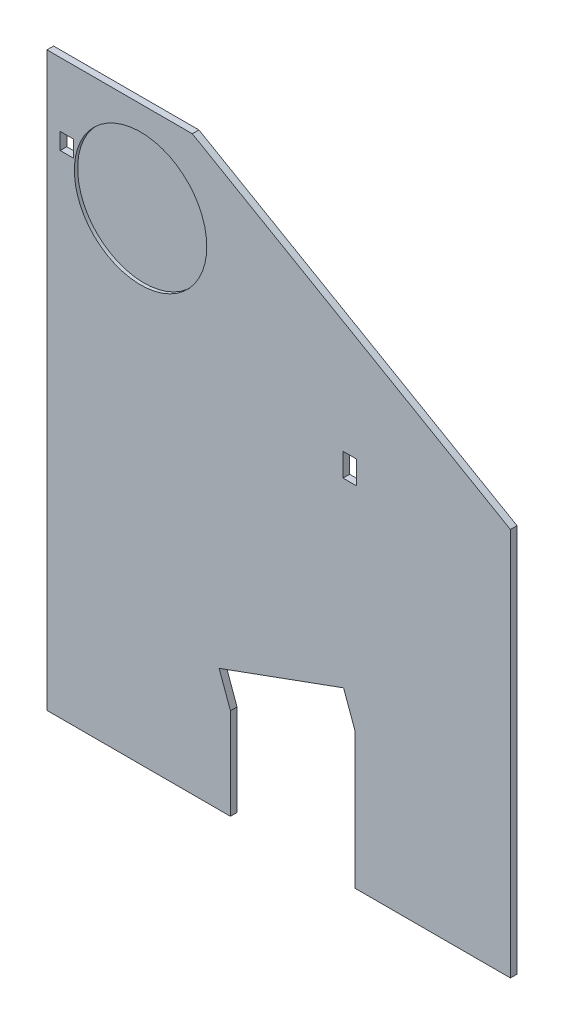
from build123d import *

# Parameters (mm, degrees)
BOSS_EXTRUDE1_DEPTH = 2
SKETCH3_W           = 4.004504799
SKETCH3_H           = 7.007808652
SKETCH3_W_2         = 4
SKETCH3_H_2         = 5
CUT_EXTRUDE1_DEPTH  = 10
SKETCH4_R           = 20
CUT_EXTRUDE2_DEPTH  = 1


with BuildPart() as part:
    # Sketch1 → Boss-Extrude1 (new body)
    with BuildSketch(Plane.XY):
        Polygon((-70, 100), (-70, -72.799540117), (70, -72.799540117), (70, 44.524791386), (-26.08587988, 100), align=None)
    extrude(amount=BOSS_EXTRUDE1_DEPTH)

    # Sketch3 → Cut-Extrude1 (cut)
    with BuildSketch(Plane.XY.offset(2)):
        with Locations((21.429491924, 36.193920339)):
            Rectangle(SKETCH3_W, SKETCH3_H)
        with Locations((-64, 78.155444566)):
            Rectangle(SKETCH3_W_2, SKETCH3_H_2)
        Polygon((-14.572335871, -75.184527756), (23.015368961, -75.184527756), (23.015368961, -31.503722023), (19.595167527, -22.106795815), (-17.992537304, -35.787601548), (-14.572335871, -45.184527756), align=None)
    extrude(amount=-CUT_EXTRUDE1_DEPTH, mode=Mode.SUBTRACT)

    # Sketch4 → Cut-Extrude2 (cut)
    with BuildSketch(Plane.XY.offset(2)):
        with Locations((-41.723720558, 72.655444566)):
            Circle(SKETCH4_R)
    extrude(amount=-CUT_EXTRUDE2_DEPTH, mode=Mode.SUBTRACT)


solid = part.part
